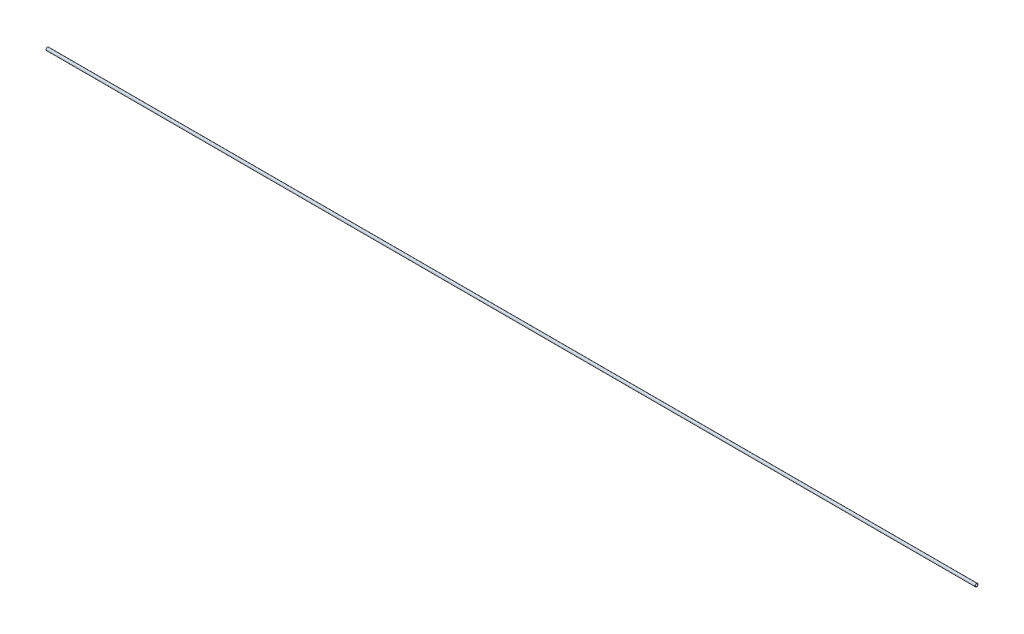
from build123d import *

# Parameters (mm, degrees)
SKETCH1_R           = 1.905
BOSS_EXTRUDE1_DEPTH = 1219.2
SKETCH2_R           = 1.5875
CUT_EXTRUDE1_DEPTH  = 1220.2


with BuildPart() as part:
    # Sketch1 → Boss-Extrude1 (new body)
    with BuildSketch(Plane(origin=(0, 0, 0), x_dir=(0, 0, -1), z_dir=(1, 0, 0))):
        Circle(SKETCH1_R)
    extrude(amount=BOSS_EXTRUDE1_DEPTH)

    # Sketch2 → Cut-Extrude1 (cut, through all)
    with BuildSketch(Plane.ZY):
        Circle(SKETCH2_R)
    extrude(amount=-CUT_EXTRUDE1_DEPTH, mode=Mode.SUBTRACT)


solid = part.part
